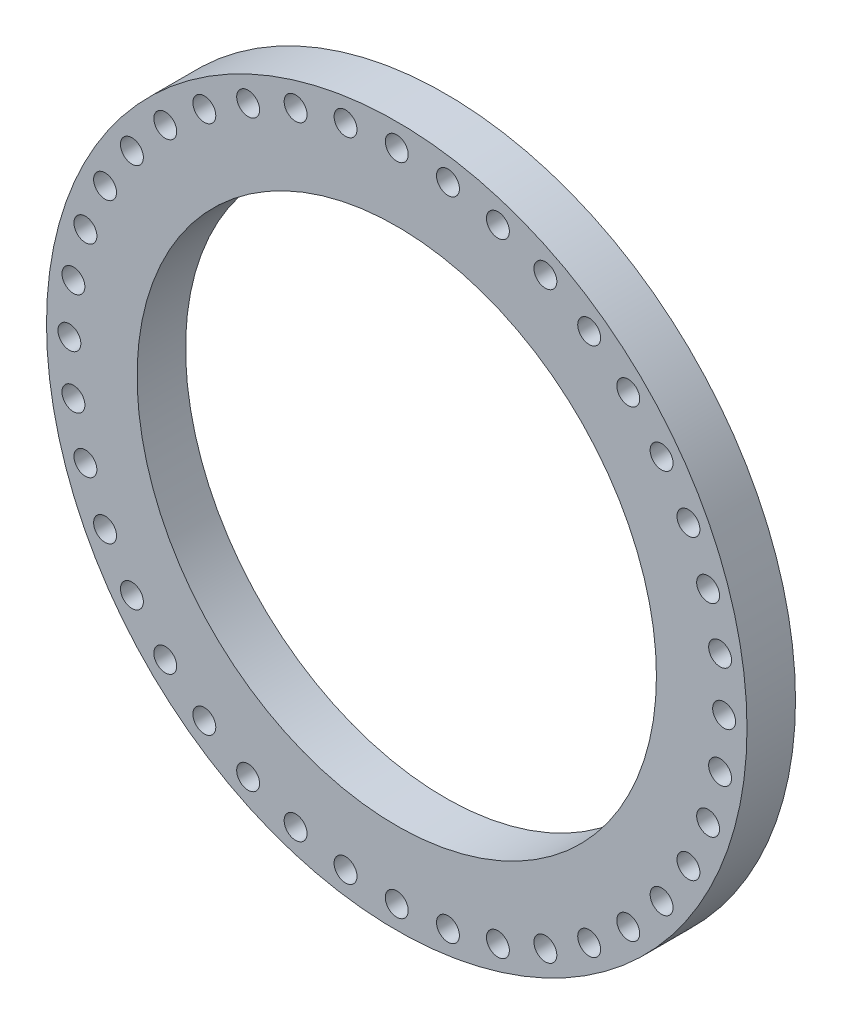
from build123d import *

# Parameters (mm, degrees)
SKETCH1_R           = 32.5
SKETCH1_R_2         = 24.095
SKETCH1_R_3         = 1.0625
BOSS_EXTRUDE1_DEPTH = 4.5
SCALE1_SCALE        = 25.4


with BuildPart() as part:
    # Sketch1 → Boss-Extrude1 (new body)
    with BuildSketch(Plane.XY):
        Circle(SKETCH1_R)
        Circle(SKETCH1_R_2, mode=Mode.SUBTRACT)
        with Locations((0, 30.375)):
            Circle(SKETCH1_R_3, mode=Mode.SUBTRACT)
        with Locations((4.751696876, 30.001033346)):
            Circle(SKETCH1_R_3, mode=Mode.SUBTRACT)
        with Locations((9.386391204, 28.888341682)):
            Circle(SKETCH1_R_3, mode=Mode.SUBTRACT)
        with Locations((13.78996143, 27.064323172)):
            Circle(SKETCH1_R_3, mode=Mode.SUBTRACT)
        with Locations((17.853977038, 24.573891204)):
            Circle(SKETCH1_R_3, mode=Mode.SUBTRACT)
        with Locations((21.478368479, 21.478368479)):
            Circle(SKETCH1_R_3, mode=Mode.SUBTRACT)
        with Locations((24.573891204, 17.853977038)):
            Circle(SKETCH1_R_3, mode=Mode.SUBTRACT)
        with Locations((27.064323172, 13.78996143)):
            Circle(SKETCH1_R_3, mode=Mode.SUBTRACT)
        with Locations((28.888341682, 9.386391204)):
            Circle(SKETCH1_R_3, mode=Mode.SUBTRACT)
        with Locations((30.001033346, 4.751696876)):
            Circle(SKETCH1_R_3, mode=Mode.SUBTRACT)
        with Locations((30.375, 0)):
            Circle(SKETCH1_R_3, mode=Mode.SUBTRACT)
        with Locations((30.001033346, -4.751696876)):
            Circle(SKETCH1_R_3, mode=Mode.SUBTRACT)
        with Locations((28.888341682, -9.386391204)):
            Circle(SKETCH1_R_3, mode=Mode.SUBTRACT)
        with Locations((27.064323172, -13.78996143)):
            Circle(SKETCH1_R_3, mode=Mode.SUBTRACT)
        with Locations((24.573891204, -17.853977038)):
            Circle(SKETCH1_R_3, mode=Mode.SUBTRACT)
        with Locations((21.478368479, -21.478368479)):
            Circle(SKETCH1_R_3, mode=Mode.SUBTRACT)
        with Locations((17.853977038, -24.573891204)):
            Circle(SKETCH1_R_3, mode=Mode.SUBTRACT)
        with Locations((13.78996143, -27.064323172)):
            Circle(SKETCH1_R_3, mode=Mode.SUBTRACT)
        with Locations((9.386391204, -28.888341682)):
            Circle(SKETCH1_R_3, mode=Mode.SUBTRACT)
        with Locations((4.751696876, -30.001033346)):
            Circle(SKETCH1_R_3, mode=Mode.SUBTRACT)
        with Locations((0, -30.375)):
            Circle(SKETCH1_R_3, mode=Mode.SUBTRACT)
        with Locations((-4.751696876, -30.001033346)):
            Circle(SKETCH1_R_3, mode=Mode.SUBTRACT)
        with Locations((-9.386391204, -28.888341682)):
            Circle(SKETCH1_R_3, mode=Mode.SUBTRACT)
        with Locations((-13.78996143, -27.064323172)):
            Circle(SKETCH1_R_3, mode=Mode.SUBTRACT)
        with Locations((-17.853977038, -24.573891204)):
            Circle(SKETCH1_R_3, mode=Mode.SUBTRACT)
        with Locations((-21.478368479, -21.478368479)):
            Circle(SKETCH1_R_3, mode=Mode.SUBTRACT)
        with Locations((-24.573891204, -17.853977038)):
            Circle(SKETCH1_R_3, mode=Mode.SUBTRACT)
        with Locations((-27.064323172, -13.78996143)):
            Circle(SKETCH1_R_3, mode=Mode.SUBTRACT)
        with Locations((-28.888341682, -9.386391204)):
            Circle(SKETCH1_R_3, mode=Mode.SUBTRACT)
        with Locations((-30.001033346, -4.751696876)):
            Circle(SKETCH1_R_3, mode=Mode.SUBTRACT)
        with Locations((-30.375, 0)):
            Circle(SKETCH1_R_3, mode=Mode.SUBTRACT)
        with Locations((-30.001033346, 4.751696876)):
            Circle(SKETCH1_R_3, mode=Mode.SUBTRACT)
        with Locations((-28.888341682, 9.386391204)):
            Circle(SKETCH1_R_3, mode=Mode.SUBTRACT)
        with Locations((-27.064323172, 13.78996143)):
            Circle(SKETCH1_R_3, mode=Mode.SUBTRACT)
        with Locations((-24.573891204, 17.853977038)):
            Circle(SKETCH1_R_3, mode=Mode.SUBTRACT)
        with Locations((-21.478368479, 21.478368479)):
            Circle(SKETCH1_R_3, mode=Mode.SUBTRACT)
        with Locations((-17.853977038, 24.573891204)):
            Circle(SKETCH1_R_3, mode=Mode.SUBTRACT)
        with Locations((-13.78996143, 27.064323172)):
            Circle(SKETCH1_R_3, mode=Mode.SUBTRACT)
        with Locations((-9.386391204, 28.888341682)):
            Circle(SKETCH1_R_3, mode=Mode.SUBTRACT)
        with Locations((-4.751696876, 30.001033346)):
            Circle(SKETCH1_R_3, mode=Mode.SUBTRACT)
    extrude(amount=BOSS_EXTRUDE1_DEPTH)


with BuildPart() as part_1:
    # Scale1: scaled about (0, 0, 2.25)
    add(part.part.scale(SCALE1_SCALE).moved(Location((0, 0, -54.9))))


solid = part_1.part
